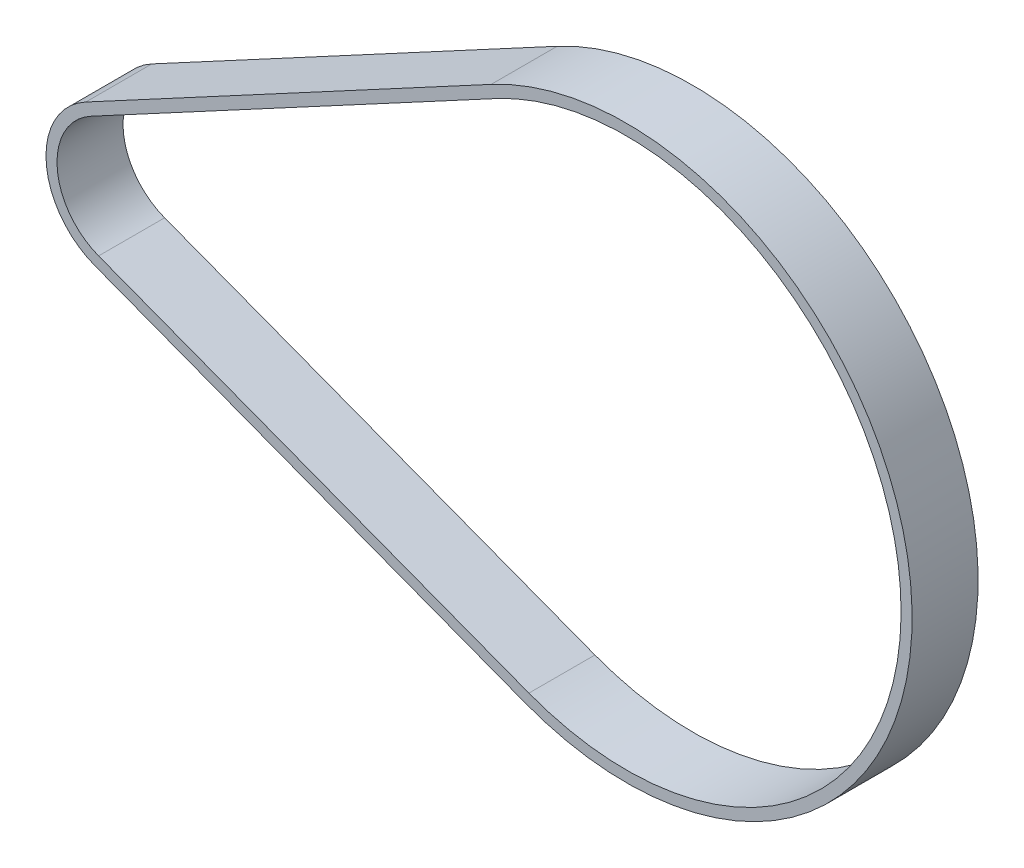
from build123d import *

# Parameters (mm, degrees)
EXTRUDE_THIN1_START = -1.5
EXTRUDE_THIN1_DEPTH = 6


with BuildPart() as part:
    # Sketch2 → Extrude-Thin1 (new body)
    with BuildSketch(Plane.XY.offset(EXTRUDE_THIN1_START)):
        with BuildLine():
            Line((-3.156917352, 2.547014688), (33.695464656, 22.363618757))
            ThreePointArc((33.695464656, 22.363618757), (71.902398785, 1.185603667), (36.771000527, -24.777119516))
            Line((36.771000527, -24.777119516), (-2.343762961, -9.916731441))
            ThreePointArc((-2.343762961, -9.916731441), (-6.75609114, -3.946199867), (-3.156917352, 2.547014688))
        make_face()
        with BuildLine():
            Line((-2.683317588, 1.666274509), (34.16906442, 21.482878578))
            ThreePointArc((34.16906442, 21.482878578), (70.904520247, 1.120500503), (37.126150999, -23.842310369))
            Line((37.126150999, -23.842310369), (-1.988612489, -8.981922293))
            ThreePointArc((-1.988612489, -8.981922293), (-5.758212601, -3.881096703), (-2.683317588, 1.666274509))
        make_face(mode=Mode.SUBTRACT)
    extrude(amount=-EXTRUDE_THIN1_DEPTH)


solid = part.part
